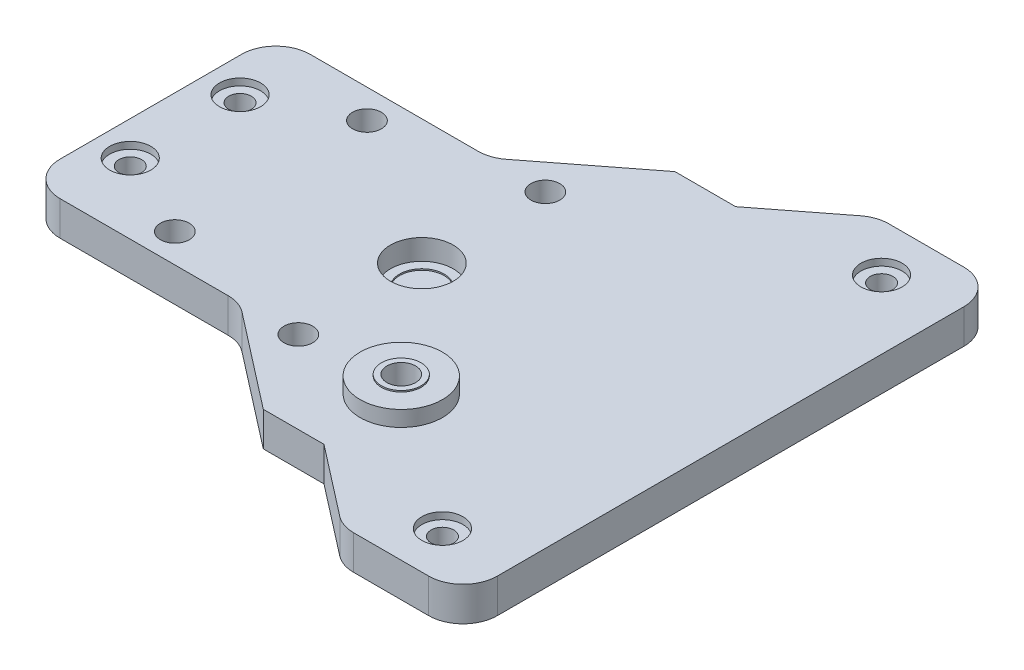
from build123d import *

# Parameters (mm, degrees)
SKETCH1_W           = 115
SKETCH1_H           = 60
SKETCH1_R           = 2.1
BOSS_EXTRUDE1_DEPTH = 5
SKETCH2_R           = 4.575
CUT_EXTRUDE1_DEPTH  = 3
SKETCH3_R           = 3.25
CUT_EXTRUDE2_DEPTH  = 0.2
SKETCH4_R           = 1.65
CUT_EXTRUDE3_DEPTH  = 6
CUT_EXTRUDE4_DEPTH  = 6
BOSS_EXTRUDE2_DEPTH = 5
SKETCH8_R           = 1.65
CUT_EXTRUDE5_DEPTH  = 6
FILLET1_R           = 5
SKETCH9_R           = 6
SKETCH9_R_2         = 2.1
BOSS_EXTRUDE3_DEPTH = 2.275
SKETCH10_R          = 2.9
SKETCH10_R_2        = 2.1
BOSS_EXTRUDE4_DEPTH = 0.2
SKETCH11_R          = 3
CUT_EXTRUDE6_DEPTH  = 1


with BuildPart() as part:
    # Sketch1 → Boss-Extrude1 (new body)
    with BuildSketch(Plane(origin=(0, 0, 0), x_dir=(1, 0, 0), z_dir=(0, 1, 0))):
        with Locations((-12.5, 0)):
            Rectangle(SKETCH1_W, SKETCH1_H)
        with Locations((-22, 14)):
            Circle(SKETCH1_R, mode=Mode.SUBTRACT)
        with Locations((0, 18)):
            Circle(SKETCH1_R, mode=Mode.SUBTRACT)
        with Locations((0, -18)):
            Circle(SKETCH1_R, mode=Mode.SUBTRACT)
        with Locations((-22, -14)):
            Circle(SKETCH1_R, mode=Mode.SUBTRACT)
        with Locations((15, -18)):
            Circle(SKETCH1_R, mode=Mode.SUBTRACT)
    extrude(amount=BOSS_EXTRUDE1_DEPTH)

    # Sketch2 → Cut-Extrude1 (cut)
    with BuildSketch(Plane(origin=(0, 5, 0), x_dir=(1, 0, 0), z_dir=(0, 1, 0))):
        Circle(SKETCH2_R)
    extrude(amount=-CUT_EXTRUDE1_DEPTH, mode=Mode.SUBTRACT)

    # Sketch3 → Cut-Extrude2 (cut)
    with BuildSketch(Plane(origin=(0, 2, 0), x_dir=(1, 0, 0), z_dir=(0, 1, 0))):
        Circle(SKETCH3_R)
    extrude(amount=-CUT_EXTRUDE2_DEPTH, mode=Mode.SUBTRACT)

    # Sketch4 → Cut-Extrude3 (cut, through all)
    with BuildSketch(Plane(origin=(0, 5, 0), x_dir=(1, 0, 0), z_dir=(0, 1, 0))):
        with Locations((-34.5, -8)):
            Circle(SKETCH4_R)
        with Locations((-34.5, 8)):
            Circle(SKETCH4_R)
    extrude(amount=-CUT_EXTRUDE3_DEPTH, mode=Mode.SUBTRACT)

    # Sketch6 → Cut-Extrude4 (cut, through all)
    with BuildSketch(Plane(origin=(0, 5, 0), x_dir=(1, 0, 0), z_dir=(0, 1, 0))):
        with BuildLine():
            Line((-22, 18.221576202), (-34.5, 18.221576202))
            ThreePointArc((-34.5, 18.221576202), (-38.035533906, 16.757110108), (-39.5, 13.221576202))
            Line((-39.5, 13.221576202), (-39.5, -13.221576202))
            ThreePointArc((-39.5, -13.221576202), (-38.035533906, -16.757110108), (-34.5, -18.221576202))
            Line((-34.5, -18.221576202), (-22, -18.221576202))
            Line((-22, -18.221576202), (-8.297519941, -18.221576202))
            Line((-8.297519941, -18.221576202), (14.635521586, -36.006383916))
            Line((14.635521586, -36.006383916), (-22, -30))
            Line((-22, -30), (-70, -30))
            Line((-70, -30), (-70, 30))
            Line((-70, 30), (-22, 30))
            Line((-22, 30), (16.094767965, 37.138044373))
            Line((16.094767965, 37.138044373), (-8.297519941, 18.221576202))
            Line((-8.297519941, 18.221576202), (-22, 18.221576202))
        make_face()
    extrude(amount=-CUT_EXTRUDE4_DEPTH, mode=Mode.SUBTRACT)

    # Sketch7 → Boss-Extrude2 (add)
    with BuildSketch(Plane(origin=(0, 5, 0), x_dir=(1, 0, 0), z_dir=(0, 1, 0))):
        Polygon((27.342211368, 39), (15.73694821, 30), (45, 30), (45, 39), align=None)
        Polygon((45, -30), (15.73694821, -30), (27.342211368, -39), (45, -39), align=None)
    extrude(amount=-BOSS_EXTRUDE2_DEPTH)

    # Sketch8 → Cut-Extrude5 (cut, through all)
    with BuildSketch(Plane(origin=(0, 5, 0), x_dir=(1, 0, 0), z_dir=(0, 1, 0))):
        with Locations((35, 32)):
            Circle(SKETCH8_R)
        with Locations((35, -32)):
            Circle(SKETCH8_R)
    extrude(amount=-CUT_EXTRUDE5_DEPTH, mode=Mode.SUBTRACT)

    # Fillet1
    fillet1_edges = [part.edges().sort_by_distance(p)[0] for p in [
        (45, 2.5, -39),
        (27.342211368, 2.5, -39),
        (27.342211368, 2.5, 39),
        (45, 2.5, 39),
        (-8.297519941, 2.5, 18.221576202),
        (-8.297519941, 2.5, -18.221576202),
    ]]
    fillet(fillet1_edges, radius=FILLET1_R)

    # Sketch9 → Boss-Extrude3 (add)
    with BuildSketch(Plane(origin=(0, 5, 0), x_dir=(1, 0, 0), z_dir=(0, 1, 0))):
        with Locations((15, -18)):
            Circle(SKETCH9_R)
        with Locations((15, -18)):
            Circle(SKETCH9_R_2, mode=Mode.SUBTRACT)
    extrude(amount=BOSS_EXTRUDE3_DEPTH)

    # Sketch10 → Boss-Extrude4 (add)
    with BuildSketch(Plane(origin=(0, 7.275, 0), x_dir=(1, 0, 0), z_dir=(0, 1, 0))):
        with Locations((15, -18)):
            Circle(SKETCH10_R)
        with Locations((15, -18)):
            Circle(SKETCH10_R_2, mode=Mode.SUBTRACT)
    extrude(amount=BOSS_EXTRUDE4_DEPTH)

    # Sketch11 → Cut-Extrude6 (cut)
    with BuildSketch(Plane(origin=(0, 5, 0), x_dir=(1, 0, 0), z_dir=(0, 1, 0))):
        with Locations((-34.5, 8)):
            Circle(SKETCH11_R)
        with Locations((-34.5, -8)):
            Circle(SKETCH11_R)
        with Locations((35, -32)):
            Circle(SKETCH11_R)
        with Locations((35, 32)):
            Circle(SKETCH11_R)
    extrude(amount=-CUT_EXTRUDE6_DEPTH, mode=Mode.SUBTRACT)


solid = part.part
